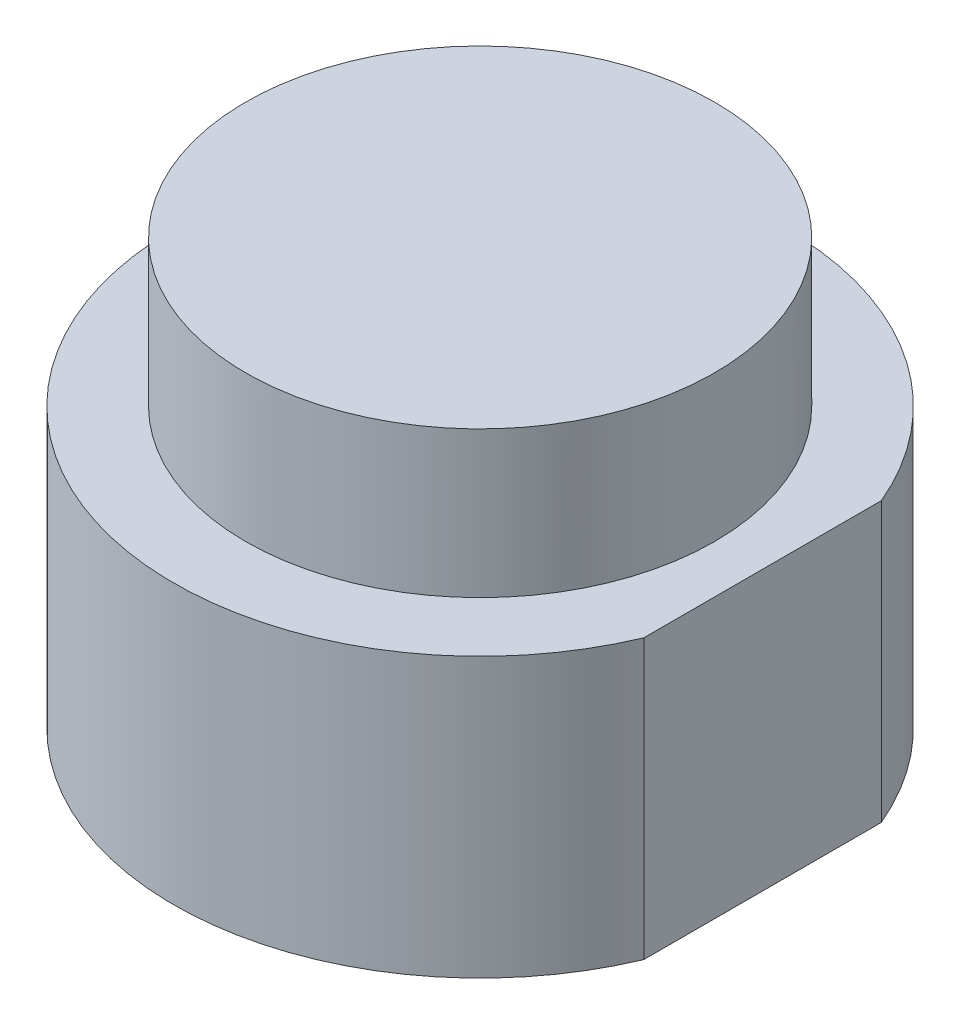
from build123d import *

# Parameters (mm, degrees)
SKETCH_1_R          = 26
EXTRUDE_1_DEPTH     = 23.65
SKETCH_2_R          = 19.9
EXTRUDE_2_DEPTH     = 36.05
CUT_EXTRUDE_1_DEPTH = 36.05
SKETCH_4_R          = 1.25
CUT_EXTRUDE_2_DEPTH = 2


with BuildPart() as part:
    # 草图1 → 凸台-拉伸1 (new body)
    with BuildSketch(Plane(origin=(0, 0, 0), x_dir=(1, 0, 0), z_dir=(0, 1, 0))):
        Circle(SKETCH_1_R)
    extrude(amount=EXTRUDE_1_DEPTH)

    # 草图2 → 凸台-拉伸2 (add)
    with BuildSketch(Plane.XZ):
        Circle(SKETCH_2_R)
    extrude(amount=-EXTRUDE_2_DEPTH)

    # 草图3 → 切除-拉伸1 (cut)
    with BuildSketch(Plane.XZ):
        with BuildLine():
            Line((23.966938911, 10.078980068), (23.966938911, -10.078980068))
            ThreePointArc((23.966938911, -10.078980068), (26, 0), (23.966938911, 10.078980068))
        make_face()
    extrude(amount=-CUT_EXTRUDE_1_DEPTH, mode=Mode.SUBTRACT)

    # 草图4 → 切除-拉伸2 (cut)
    with BuildSketch(Plane.XZ):
        with Locations((-14.000714267, -14.000714267)):
            Circle(SKETCH_4_R)
        with Locations((14.000714267, 14.000714267)):
            Circle(SKETCH_4_R)
    extrude(amount=-CUT_EXTRUDE_2_DEPTH, mode=Mode.SUBTRACT)


solid = part.part
